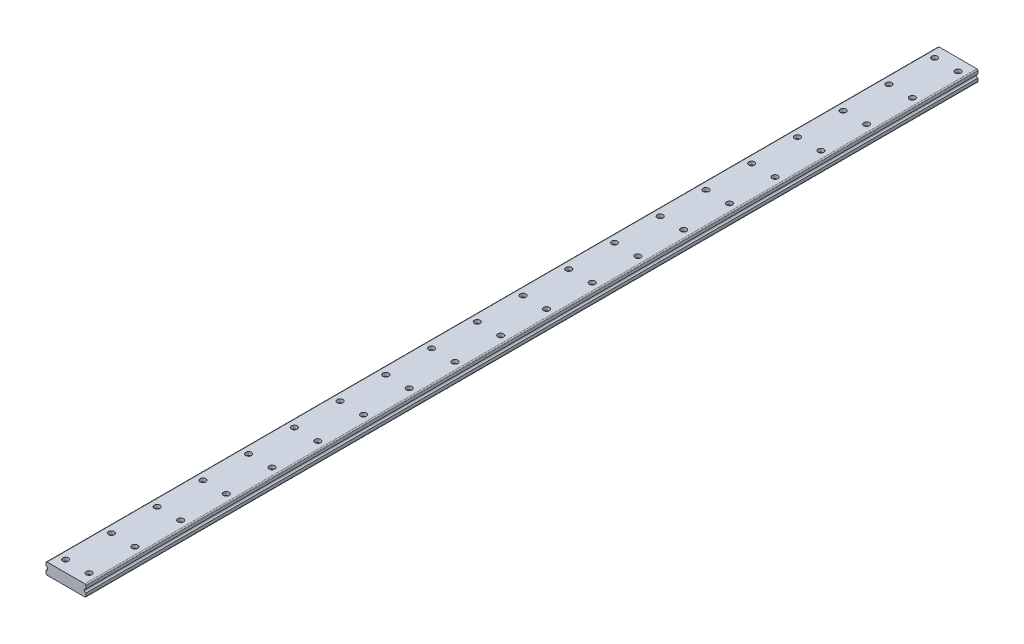
from build123d import *

# Parameters (mm, degrees)
BOSS_EXTRUDE1_DEPTH = 1560.45
SKETCH2_R           = 5.05
CUT_EXTRUDE1_DEPTH  = 6
LPATTERN1_COUNT     = 20
LPATTERN1_PITCH     = 80


with BuildPart() as part:
    # Sketch1 → Boss-Extrude1 (new body)
    with BuildSketch(Plane.XY):
        with BuildLine():
            Line((0, 13), (0, 18))
            ThreePointArc((0, 18), (0.585786438, 19.414213562), (2, 20))
            Line((2, 20), (67.85, 20))
            ThreePointArc((67.85, 20), (69.264213562, 19.414213562), (69.85, 18))
            Line((69.85, 18), (69.85, 13))
            ThreePointArc((69.85, 13), (66.85, 10), (69.85, 7))
            Line((69.85, 7), (69.85, 2))
            ThreePointArc((69.85, 2), (69.264213562, 0.585786438), (67.85, 0))
            Line((67.85, 0), (2, 0))
            ThreePointArc((2, 0), (0.585786438, 0.585786438), (0, 2))
            Line((0, 2), (0, 7))
            ThreePointArc((0, 7), (3, 10), (0, 13))
        make_face()
    extrude(amount=BOSS_EXTRUDE1_DEPTH)

    # Sketch2 → Cut-Extrude1 (cut)
    with BuildSketch(Plane(origin=(0, 20, 0), x_dir=(1, 0, 0), z_dir=(0, 1, 0))):
        with Locations((14.425, -1540.45)):
            Circle(SKETCH2_R)
        with Locations((55.425, -1540.45)):
            Circle(SKETCH2_R)
    cut_extrude1 = extrude(amount=-CUT_EXTRUDE1_DEPTH, mode=Mode.SUBTRACT)

    # LPattern1: Cut-Extrude1 ×20
    with Locations(*[(0, 0, -i * LPATTERN1_PITCH) for i in range(1, LPATTERN1_COUNT)]):
        add(cut_extrude1, mode=Mode.SUBTRACT)


solid = part.part
